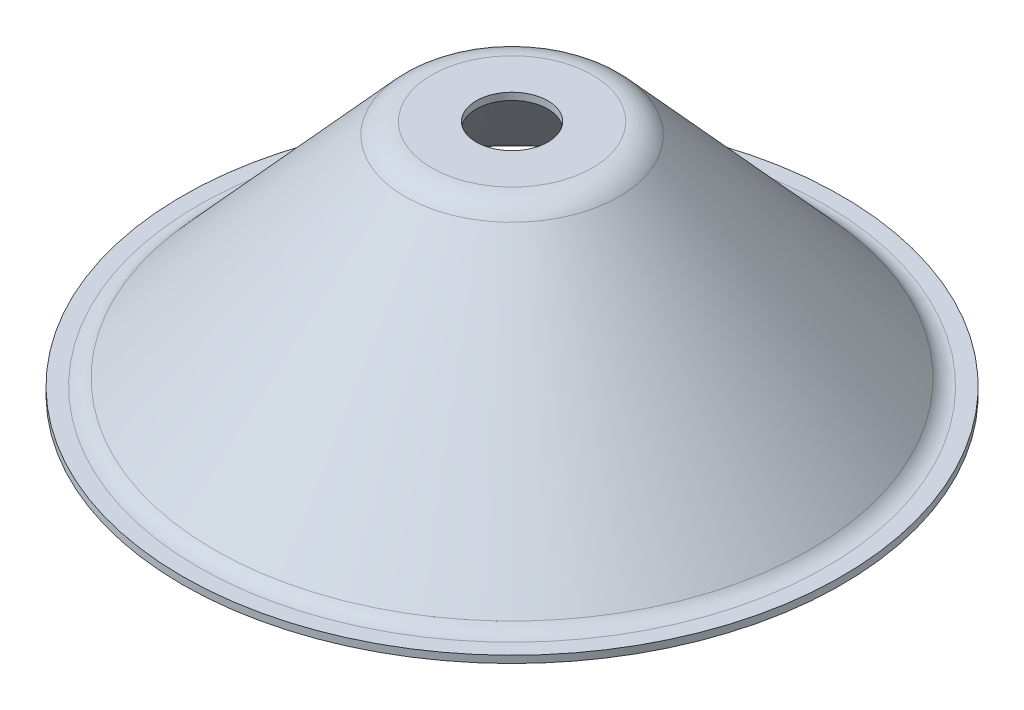
from build123d import *


with BuildPart() as part:
    # Sketch1 → Revolve-Thin1 (revolve)
    with BuildSketch(Plane.XY):
        with BuildLine():
            Line((5, 0), (11.22679428, 0))
            ThreePointArc((11.22679428, 0), (12.84785708, -0.343204217), (14.190742085, -1.313922301))
            Line((14.190742085, -1.313922301), (40.809257915, -30.686077699))
            ThreePointArc((40.809257915, -30.686077699), (42.15214292, -31.656795783), (43.77320572, -32))
            Line((43.77320572, -32), (46, -32))
            Line((46, -32), (46, -31))
            Line((46, -31), (43.77320572, -31))
            ThreePointArc((43.77320572, -31), (42.55740862, -30.742596837), (41.550244866, -30.014558274))
            Line((41.550244866, -30.014558274), (14.931729037, -0.642402876))
            ThreePointArc((14.931729037, -0.642402876), (13.25312278, 0.570994729), (11.22679428, 1))
            Line((11.22679428, 1), (5, 1))
            Line((5, 1), (5, 0))
        make_face()
    revolve(axis=Axis((0, 23.415841584, 0), (0, -1, 0)))


solid = part.part
